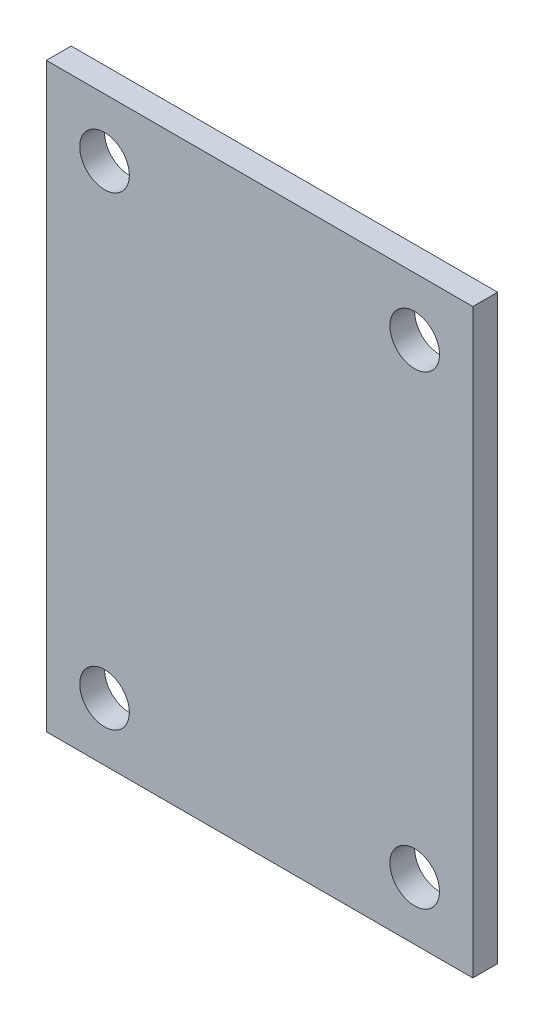
from build123d import *

# Parameters (mm, degrees)
SKETCH_1_W      = 27.5
SKETCH_1_H      = 37.5
SKETCH_1_R      = 1.6
EXTRUDE_1_DEPTH = 1.6


with BuildPart() as part:
    # Эскиз1 → Бобышка-Вытянуть1 (new body)
    with BuildSketch(Plane.XY):
        Rectangle(SKETCH_1_W, SKETCH_1_H)
        with Locations((-10, 15)):
            Circle(SKETCH_1_R, mode=Mode.SUBTRACT)
        with Locations((10, 15)):
            Circle(SKETCH_1_R, mode=Mode.SUBTRACT)
        with Locations((10, -15)):
            Circle(SKETCH_1_R, mode=Mode.SUBTRACT)
        with Locations((-10, -15)):
            Circle(SKETCH_1_R, mode=Mode.SUBTRACT)
    extrude(amount=EXTRUDE_1_DEPTH)


solid = part.part
